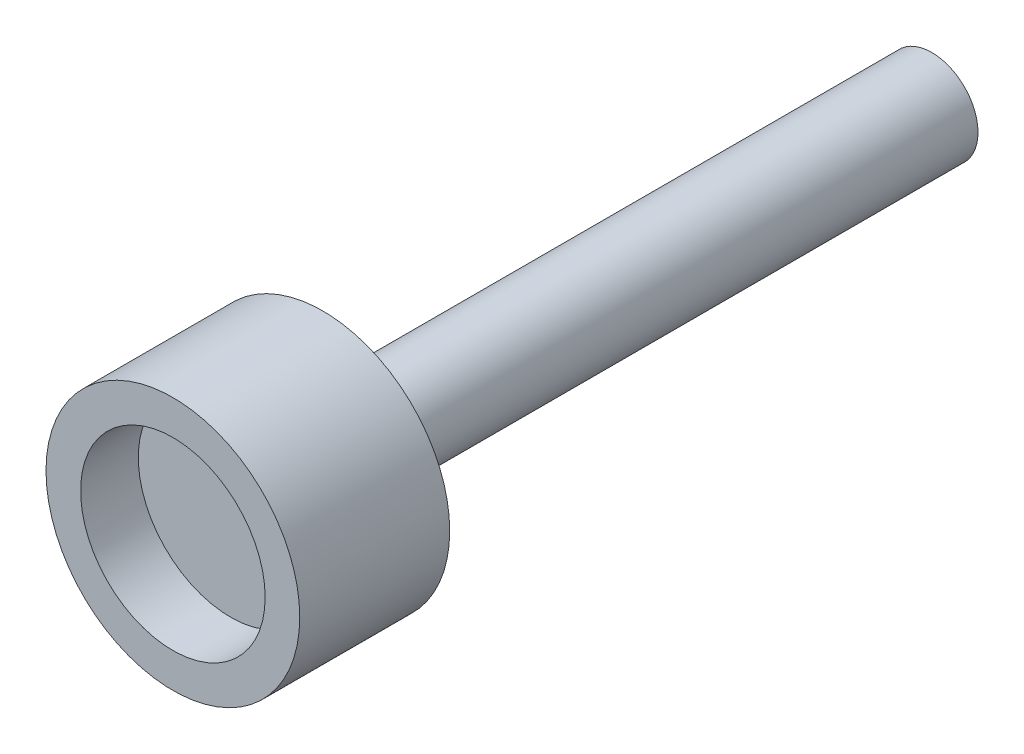
from build123d import *

# Parameters (mm, degrees)
CROQUIS1_R              = 11
SALIENTE_EXTRUIR1_DEPTH = 13
CROQUIS2_R              = 8
CORTAR_EXTRUIR1_DEPTH   = 5
CROQUIS3_R              = 1.5
CORTAR_EXTRUIR2_DEPTH   = 15
CROQUIS4_R              = 4
SALIENTE_EXTRUIR2_DEPTH = 52.8


with BuildPart() as part:
    # Croquis1 → Saliente-Extruir1 (new body)
    with BuildSketch(Plane.XY):
        Circle(CROQUIS1_R)
    extrude(amount=SALIENTE_EXTRUIR1_DEPTH)

    # Croquis2 → Cortar-Extruir1 (cut)
    with BuildSketch(Plane.XY.offset(13)):
        Circle(CROQUIS2_R)
    extrude(amount=-CORTAR_EXTRUIR1_DEPTH, mode=Mode.SUBTRACT)

    # Croquis3 → Cortar-Extruir2 (cut)
    with BuildSketch(Plane(origin=(0, 0, 0), x_dir=(0, 0, -1), z_dir=(1, 0, 0))):
        with Locations((-5, 0)):
            Circle(CROQUIS3_R)
    extrude(amount=-CORTAR_EXTRUIR2_DEPTH, mode=Mode.SUBTRACT)

    # Croquis4 → Saliente-Extruir2 (add)
    with BuildSketch(Plane(origin=(0, 0, 0), x_dir=(-1, 0, 0), z_dir=(0, 0, -1))):
        Circle(CROQUIS4_R)
    extrude(amount=SALIENTE_EXTRUIR2_DEPTH)


solid = part.part
